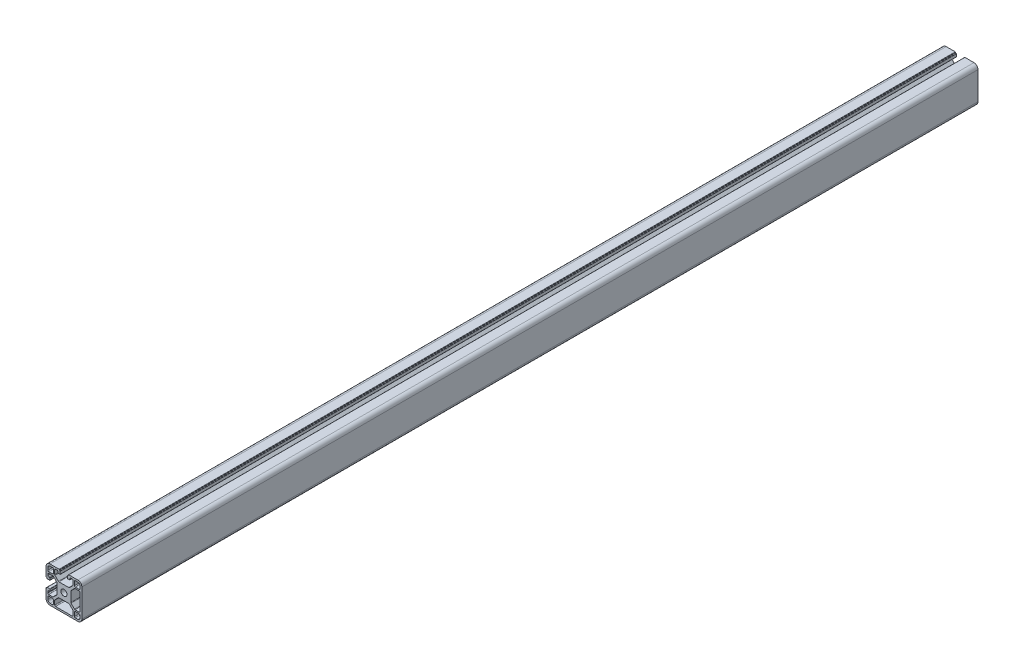
from build123d import *

# Parameters (mm, degrees)
SKETCH_1_R      = 3.4
EXTRUDE_1_DEPTH = 1000


with BuildPart() as part:
    # Эскиз1 → Бобышка-Вытянуть1 (new body)
    with BuildSketch(Plane.XY):
        with BuildLine():
            Line((-20, 15.5), (-20, 10.25))
            Line((-20, 10.25), (-20, 5.4))
            ThreePointArc((-20, 5.4), (-19.912132034, 5.187867966), (-19.7, 5.1))
            Line((-19.7, 5.1), (-19.3, 5.1))
            ThreePointArc((-19.3, 5.1), (-19.087867966, 5.012132034), (-19, 4.8))
            Line((-19, 4.8), (-19, 4.4))
            ThreePointArc((-19, 4.4), (-18.912132034, 4.187867966), (-18.7, 4.1))
            Line((-18.7, 4.1), (-15.8, 4.1))
            ThreePointArc((-15.8, 4.1), (-15.587867966, 4.187867966), (-15.5, 4.4))
            Line((-15.5, 4.4), (-15.5, 6.3))
            ThreePointArc((-15.5, 6.3), (-15.587867966, 6.512132034), (-15.8, 6.6))
            Line((-15.8, 6.6), (-17, 6.6))
            ThreePointArc((-17, 6.6), (-17.707106781, 6.892893219), (-18, 7.6))
            Line((-18, 7.6), (-18, 9.25))
            ThreePointArc((-18, 9.25), (-17.707106781, 9.957106781), (-17, 10.25))
            Line((-17, 10.25), (-12.464213562, 10.25))
            ThreePointArc((-12.464213562, 10.25), (-12.08153013, 10.173879533), (-11.757106781, 9.957106781))
            Line((-11.757106781, 9.957106781), (-7.992893219, 6.192893219))
            ThreePointArc((-7.992893219, 6.192893219), (-7.776120467, 5.86846987), (-7.7, 5.485786438))
            Line((-7.7, 5.485786438), (-7.7, -5.485786438))
            ThreePointArc((-7.7, -5.485786438), (-7.776120467, -5.86846987), (-7.992893219, -6.192893219))
            Line((-7.992893219, -6.192893219), (-11.757106781, -9.957106781))
            ThreePointArc((-11.757106781, -9.957106781), (-12.08153013, -10.173879533), (-12.464213562, -10.25))
            Line((-12.464213562, -10.25), (-17, -10.25))
            ThreePointArc((-17, -10.25), (-17.707106781, -9.957106781), (-18, -9.25))
            Line((-18, -9.25), (-18, -7.6))
            ThreePointArc((-18, -7.6), (-17.707106781, -6.892893219), (-17, -6.6))
            Line((-17, -6.6), (-15.8, -6.6))
            ThreePointArc((-15.8, -6.6), (-15.587867966, -6.512132034), (-15.5, -6.3))
            Line((-15.5, -6.3), (-15.5, -4.4))
            ThreePointArc((-15.5, -4.4), (-15.587867966, -4.187867966), (-15.8, -4.1))
            Line((-15.8, -4.1), (-18.7, -4.1))
            ThreePointArc((-18.7, -4.1), (-18.912132034, -4.187867966), (-19, -4.4))
            Line((-19, -4.4), (-19, -4.8))
            ThreePointArc((-19, -4.8), (-19.087867966, -5.012132034), (-19.3, -5.1))
            Line((-19.3, -5.1), (-19.7, -5.1))
            ThreePointArc((-19.7, -5.1), (-19.912132034, -5.187867966), (-20, -5.4))
            Line((-20, -5.4), (-20, -10.25))
            Line((-20, -10.25), (-20, -15.5))
            ThreePointArc((-20, -15.5), (-18.681980515, -18.681980515), (-15.5, -20))
            Line((-15.5, -20), (-10.25, -20))
            Line((-10.25, -20), (0, -20))
            Line((0, -20), (10.25, -20))
            Line((10.25, -20), (15.5, -20))
            ThreePointArc((15.5, -20), (18.681980515, -18.681980515), (20, -15.5))
            Line((20, -15.5), (20, -10.25))
            Line((20, -10.25), (20, 0))
            Line((20, 0), (20, 10.25))
            Line((20, 10.25), (20, 15.5))
            ThreePointArc((20, 15.5), (18.681980515, 18.681980515), (15.5, 20))
            Line((15.5, 20), (10.25, 20))
            Line((10.25, 20), (5.4, 20))
            ThreePointArc((5.4, 20), (5.187867966, 19.912132034), (5.1, 19.7))
            Line((5.1, 19.7), (5.1, 19.3))
            ThreePointArc((5.1, 19.3), (5.012132034, 19.087867966), (4.8, 19))
            Line((4.8, 19), (4.4, 19))
            ThreePointArc((4.4, 19), (4.187867966, 18.912132034), (4.1, 18.7))
            Line((4.1, 18.7), (4.1, 15.8))
            ThreePointArc((4.1, 15.8), (4.187867966, 15.587867966), (4.4, 15.5))
            Line((4.4, 15.5), (6.3, 15.5))
            ThreePointArc((6.3, 15.5), (6.512132034, 15.587867966), (6.6, 15.8))
            Line((6.6, 15.8), (6.6, 17))
            ThreePointArc((6.6, 17), (6.892893219, 17.707106781), (7.6, 18))
            Line((7.6, 18), (9.25, 18))
            ThreePointArc((9.25, 18), (9.957106781, 17.707106781), (10.25, 17))
            Line((10.25, 17), (10.25, 12.464213562))
            ThreePointArc((10.25, 12.464213562), (10.173879533, 12.08153013), (9.957106781, 11.757106781))
            Line((9.957106781, 11.757106781), (6.192893219, 7.992893219))
            ThreePointArc((6.192893219, 7.992893219), (5.86846987, 7.776120467), (5.485786438, 7.7))
            Line((5.485786438, 7.7), (-5.485786438, 7.7))
            ThreePointArc((-5.485786438, 7.7), (-5.86846987, 7.776120467), (-6.192893219, 7.992893219))
            Line((-6.192893219, 7.992893219), (-9.957106781, 11.757106781))
            ThreePointArc((-9.957106781, 11.757106781), (-10.173879533, 12.08153013), (-10.25, 12.464213562))
            Line((-10.25, 12.464213562), (-10.25, 17))
            ThreePointArc((-10.25, 17), (-9.957106781, 17.707106781), (-9.25, 18))
            Line((-9.25, 18), (-7.6, 18))
            ThreePointArc((-7.6, 18), (-6.892893219, 17.707106781), (-6.6, 17))
            Line((-6.6, 17), (-6.6, 15.8))
            ThreePointArc((-6.6, 15.8), (-6.512132034, 15.587867966), (-6.3, 15.5))
            Line((-6.3, 15.5), (-4.4, 15.5))
            ThreePointArc((-4.4, 15.5), (-4.187867966, 15.587867966), (-4.1, 15.8))
            Line((-4.1, 15.8), (-4.1, 18.7))
            ThreePointArc((-4.1, 18.7), (-4.187867966, 18.912132034), (-4.4, 19))
            Line((-4.4, 19), (-4.8, 19))
            ThreePointArc((-4.8, 19), (-5.012132034, 19.087867966), (-5.1, 19.3))
            Line((-5.1, 19.3), (-5.1, 19.7))
            ThreePointArc((-5.1, 19.7), (-5.187867966, 19.912132034), (-5.4, 20))
            Line((-5.4, 20), (-10.25, 20))
            Line((-10.25, 20), (-15.5, 20))
            ThreePointArc((-15.5, 20), (-18.681980515, 18.681980515), (-20, 15.5))
        make_face()
        with BuildLine():
            ThreePointArc((-12.8, -11.8), (-12.092893219, -12.092893219), (-11.8, -12.8))
            Line((-11.8, -12.8), (-11.8, -17))
            ThreePointArc((-11.8, -17), (-12.092893219, -17.707106781), (-12.8, -18))
            Line((-12.8, -18), (-15.5, -18))
            ThreePointArc((-15.5, -18), (-17.267766953, -17.267766953), (-18, -15.5))
            Line((-18, -15.5), (-18, -12.8))
            ThreePointArc((-18, -12.8), (-17.707106781, -12.092893219), (-17, -11.8))
            Line((-17, -11.8), (-12.8, -11.8))
        make_face(mode=Mode.SUBTRACT)
        with BuildLine():
            Line((9.25, -18), (0, -18))
            Line((0, -18), (-9.25, -18))
            ThreePointArc((-9.25, -18), (-9.957106781, -17.707106781), (-10.25, -17))
            Line((-10.25, -17), (-10.25, -12.464213562))
            ThreePointArc((-10.25, -12.464213562), (-10.173879533, -12.08153013), (-9.957106781, -11.757106781))
            Line((-9.957106781, -11.757106781), (-6.192893219, -7.992893219))
            ThreePointArc((-6.192893219, -7.992893219), (-5.86846987, -7.776120467), (-5.485786438, -7.7))
            Line((-5.485786438, -7.7), (5.485786438, -7.7))
            ThreePointArc((5.485786438, -7.7), (5.86846987, -7.776120467), (6.192893219, -7.992893219))
            Line((6.192893219, -7.992893219), (9.957106781, -11.757106781))
            ThreePointArc((9.957106781, -11.757106781), (10.173879533, -12.08153013), (10.25, -12.464213562))
            Line((10.25, -12.464213562), (10.25, -17))
            ThreePointArc((10.25, -17), (9.957106781, -17.707106781), (9.25, -18))
        make_face(mode=Mode.SUBTRACT)
        with BuildLine():
            ThreePointArc((11.8, -12.8), (12.092893219, -12.092893219), (12.8, -11.8))
            Line((12.8, -11.8), (17, -11.8))
            ThreePointArc((17, -11.8), (17.707106781, -12.092893219), (18, -12.8))
            Line((18, -12.8), (18, -15.5))
            ThreePointArc((18, -15.5), (17.267766953, -17.267766953), (15.5, -18))
            Line((15.5, -18), (12.8, -18))
            ThreePointArc((12.8, -18), (12.092893219, -17.707106781), (11.8, -17))
            Line((11.8, -17), (11.8, -12.8))
        make_face(mode=Mode.SUBTRACT)
        Circle(SKETCH_1_R, mode=Mode.SUBTRACT)
        with BuildLine():
            ThreePointArc((-11.8, 12.8), (-12.092893219, 12.092893219), (-12.8, 11.8))
            Line((-12.8, 11.8), (-17, 11.8))
            ThreePointArc((-17, 11.8), (-17.707106781, 12.092893219), (-18, 12.8))
            Line((-18, 12.8), (-18, 15.5))
            ThreePointArc((-18, 15.5), (-17.267766953, 17.267766953), (-15.5, 18))
            Line((-15.5, 18), (-12.8, 18))
            ThreePointArc((-12.8, 18), (-12.092893219, 17.707106781), (-11.8, 17))
            Line((-11.8, 17), (-11.8, 12.8))
        make_face(mode=Mode.SUBTRACT)
        with BuildLine():
            Line((18, 9.25), (18, 0))
            Line((18, 0), (18, -9.25))
            ThreePointArc((18, -9.25), (17.707106781, -9.957106781), (17, -10.25))
            Line((17, -10.25), (12.464213562, -10.25))
            ThreePointArc((12.464213562, -10.25), (12.08153013, -10.173879533), (11.757106781, -9.957106781))
            Line((11.757106781, -9.957106781), (7.992893219, -6.192893219))
            ThreePointArc((7.992893219, -6.192893219), (7.776120467, -5.86846987), (7.7, -5.485786438))
            Line((7.7, -5.485786438), (7.7, 5.485786438))
            ThreePointArc((7.7, 5.485786438), (7.776120467, 5.86846987), (7.992893219, 6.192893219))
            Line((7.992893219, 6.192893219), (11.757106781, 9.957106781))
            ThreePointArc((11.757106781, 9.957106781), (12.08153013, 10.173879533), (12.464213562, 10.25))
            Line((12.464213562, 10.25), (17, 10.25))
            ThreePointArc((17, 10.25), (17.707106781, 9.957106781), (18, 9.25))
        make_face(mode=Mode.SUBTRACT)
        with BuildLine():
            ThreePointArc((12.8, 11.8), (12.092893219, 12.092893219), (11.8, 12.8))
            Line((11.8, 12.8), (11.8, 17))
            ThreePointArc((11.8, 17), (12.092893219, 17.707106781), (12.8, 18))
            Line((12.8, 18), (15.5, 18))
            ThreePointArc((15.5, 18), (17.267766953, 17.267766953), (18, 15.5))
            Line((18, 15.5), (18, 12.8))
            ThreePointArc((18, 12.8), (17.707106781, 12.092893219), (17, 11.8))
            Line((17, 11.8), (12.8, 11.8))
        make_face(mode=Mode.SUBTRACT)
    extrude(amount=EXTRUDE_1_DEPTH)


solid = part.part
